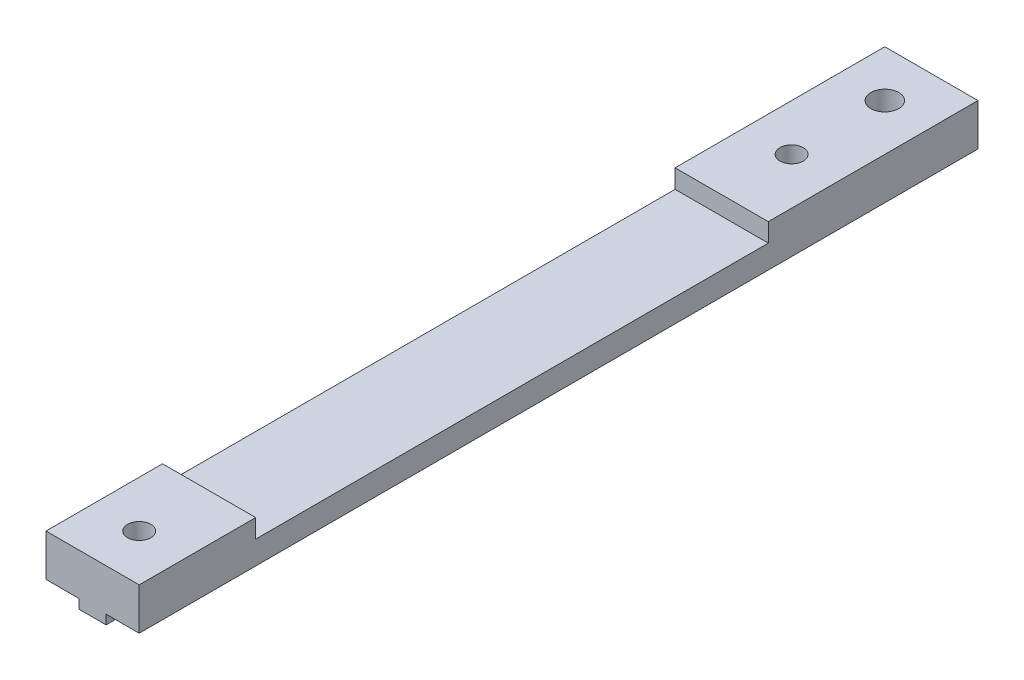
from build123d import *

# Parameters (mm, degrees)
MAIN_DEPTH      = 90
SKETCH2_R       = 1.25
SKETCH2_R_2     = 1.5
MAINHOLES_DEPTH = 6.5
SKETCH3_W       = 10
SKETCH3_H       = 55
PINHOLES_DEPTH  = 2


with BuildPart() as part:
    # Sketch1 → Main (new body)
    with BuildSketch(Plane.XY):
        Polygon((-5, 0), (5, 0), (5, -4.5), (1.45, -4.5), (1.45, -5.5), (-1.45, -5.5), (-1.45, -4.5), (-5, -4.5), align=None)
    extrude(amount=MAIN_DEPTH)

    # Sketch2 → MainHoles (cut, through all)
    with BuildSketch(Plane(origin=(0, 0, 0), x_dir=(1, 0, 0), z_dir=(0, 1, 0))):
        with Locations((0, -85)):
            Circle(SKETCH2_R)
        with Locations((0, -15)):
            Circle(SKETCH2_R)
        with Locations((0, -5)):
            Circle(SKETCH2_R_2)
    extrude(amount=-MAINHOLES_DEPTH, mode=Mode.SUBTRACT)

    # Sketch3 → PinHoles (cut)
    with BuildSketch(Plane(origin=(0, 0, 0), x_dir=(1, 0, 0), z_dir=(0, 1, 0))):
        with Locations((0, -50)):
            Rectangle(SKETCH3_W, SKETCH3_H)
    extrude(amount=-PINHOLES_DEPTH, mode=Mode.SUBTRACT)


solid = part.part
